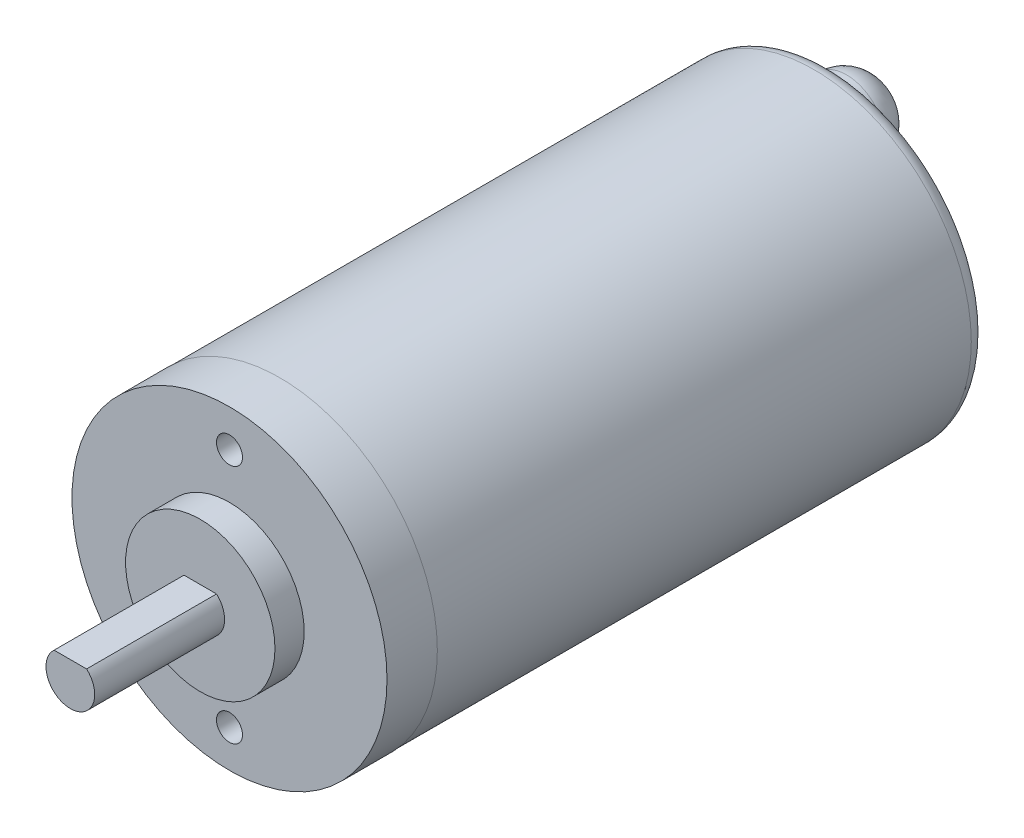
from build123d import *

# Parameters (mm, degrees)
SKETCH1_R           = 12.319
BOSS_EXTRUDE1_DEPTH = 46.99
SKETCH2_R           = 5.842
BOSS_EXTRUDE2_DEPTH = 2.286
SKETCH3_R           = 1.905
BOSS_EXTRUDE3_DEPTH = 10.16
SKETCH4_W           = 43.053
SKETCH4_H           = 0.0254
FILLET1_R           = 1.27
SKETCH5_R           = 3.048
BOSS_EXTRUDE4_DEPTH = 3.81
FILLET2_R           = 2.54
SKETCH6_R           = 1.016
CUT_EXTRUDE1_DEPTH  = 6.35
SKETCH7_W           = 2.991253898
SKETCH7_H           = 0.508
CUT_EXTRUDE2_DEPTH  = 10.16


with BuildPart() as part:
    # Sketch1 → Boss-Extrude1 (new body)
    with BuildSketch(Plane.XY):
        Circle(SKETCH1_R)
    extrude(amount=-BOSS_EXTRUDE1_DEPTH)

    # Sketch2 → Boss-Extrude2 (add)
    with BuildSketch(Plane.XY):
        Circle(SKETCH2_R)
    extrude(amount=BOSS_EXTRUDE2_DEPTH)

    # Sketch3 → Boss-Extrude3 (add)
    with BuildSketch(Plane.XY.offset(2.286)):
        Circle(SKETCH3_R)
    extrude(amount=BOSS_EXTRUDE3_DEPTH)

    # Sketch4 → Cut-Revolve1 (revolve, cut)
    with BuildSketch(Plane(origin=(0, 0, 0), x_dir=(0, 0, -1), z_dir=(1, 0, 0))):
        with Locations((25.4635, 12.3063)):
            Rectangle(SKETCH4_W, SKETCH4_H)
    revolve(axis=Axis((0, 0, -46.99), (0, 0, 1)), mode=Mode.SUBTRACT)

    # Fillet1
    fillet1_edges = [part.edges().sort_by_distance(p)[0] for p in [
        (0, -12.2936, -46.99),
    ]]
    fillet(fillet1_edges, radius=FILLET1_R)

    # Sketch5 → Boss-Extrude4 (add)
    with BuildSketch(Plane(origin=(0, 0, -46.99), x_dir=(-1, 0, 0), z_dir=(0, 0, -1))):
        with Locations((0, 7.62)):
            Circle(SKETCH5_R)
    extrude(amount=BOSS_EXTRUDE4_DEPTH)

    # Fillet2
    fillet2_edges = [part.edges().sort_by_distance(p)[0] for p in [
        (3.048, 7.62, -50.8),
    ]]
    fillet(fillet2_edges, radius=FILLET2_R)

    # Sketch6 → Cut-Extrude1 (cut)
    with BuildSketch(Plane.XY):
        with Locations((0, 9.398)):
            Circle(SKETCH6_R)
    cut_extrude1 = extrude(amount=-CUT_EXTRUDE1_DEPTH, mode=Mode.SUBTRACT)

    # Mirror1: Cut-Extrude1 across plane
    add(cut_extrude1.mirror(Plane.ZX), mode=Mode.SUBTRACT)

    # Sketch7 → Cut-Extrude2 (cut)
    with BuildSketch(Plane.XY.offset(12.446)):
        with Locations((0, 1.672065055)):
            Rectangle(SKETCH7_W, SKETCH7_H)
    extrude(amount=-CUT_EXTRUDE2_DEPTH, mode=Mode.SUBTRACT)


solid = part.part
